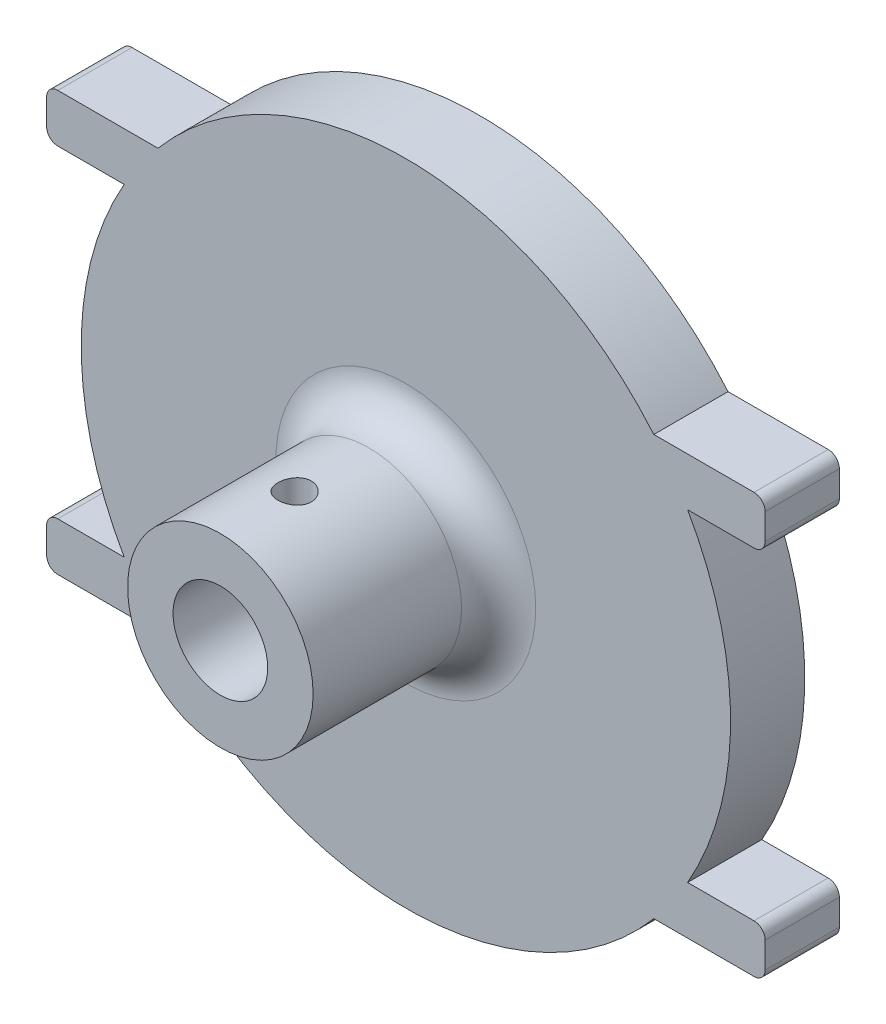
from build123d import *

# Parameters (mm, degrees)
BOSS_EXTRUDE1_DEPTH = 5.08
SKETCH5_R           = 9.6901
CUT_EXTRUDE2_DEPTH  = 2.54
SKETCH6_R           = 6.35
SKETCH6_R_2         = 3.2385
BOSS_EXTRUDE4_DEPTH = 12.7
FILLET1_R           = 2.54
SKETCH8_R           = 1.143
CUT_EXTRUDE3_DEPTH  = 7.62
SKETCH9_R           = 1.905
CUT_EXTRUDE4_DEPTH  = 16.2400001


with BuildPart() as part:
    # Sketch1 → Boss-Extrude1 (new body)
    with BuildSketch(Plane.XY):
        with BuildLine():
            Line((-23.828545778, 14.351), (-16.970545778, 14.351))
            ThreePointArc((-16.970545778, 14.351), (0, 22.225), (16.970545778, 14.351))
            Line((16.970545778, 14.351), (23.828545778, 14.351))
            ThreePointArc((23.828545778, 14.351), (24.367361145, 14.127815367), (24.590545778, 13.589))
            Line((24.590545778, 13.589), (24.590545778, 11.811))
            ThreePointArc((24.590545778, 11.811), (24.367361145, 11.272184633), (23.828545778, 11.049))
            Line((23.828545778, 11.049), (19.283936942, 11.049))
            ThreePointArc((19.283936942, 11.049), (22.225, 0), (19.283936942, -11.049))
            Line((19.283936942, -11.049), (23.828545778, -11.049))
            ThreePointArc((23.828545778, -11.049), (24.367361145, -11.272184633), (24.590545778, -11.811))
            Line((24.590545778, -11.811), (24.590545778, -13.589))
            ThreePointArc((24.590545778, -13.589), (24.367361145, -14.127815367), (23.828545778, -14.351))
            Line((23.828545778, -14.351), (16.970545778, -14.351))
            ThreePointArc((16.970545778, -14.351), (0, -22.225), (-16.970545778, -14.351))
            Line((-16.970545778, -14.351), (-23.828545778, -14.351))
            ThreePointArc((-23.828545778, -14.351), (-24.367361145, -14.127815367), (-24.590545778, -13.589))
            Line((-24.590545778, -13.589), (-24.590545778, -11.811))
            ThreePointArc((-24.590545778, -11.811), (-24.367361145, -11.272184633), (-23.828545778, -11.049))
            Line((-23.828545778, -11.049), (-19.283936942, -11.049))
            ThreePointArc((-19.283936942, -11.049), (-22.225, 0), (-19.283936942, 11.049))
            Line((-19.283936942, 11.049), (-23.828545778, 11.049))
            ThreePointArc((-23.828545778, 11.049), (-24.367361145, 11.272184633), (-24.590545778, 11.811))
            Line((-24.590545778, 11.811), (-24.590545778, 13.589))
            ThreePointArc((-24.590545778, 13.589), (-24.367361145, 14.127815367), (-23.828545778, 14.351))
        make_face()
    extrude(amount=BOSS_EXTRUDE1_DEPTH)

    # Sketch5 → Cut-Extrude2 (cut)
    with BuildSketch(Plane(origin=(0, 0, 0), x_dir=(-1, 0, 0), z_dir=(0, 0, -1))):
        Circle(SKETCH5_R)
    extrude(amount=-CUT_EXTRUDE2_DEPTH, mode=Mode.SUBTRACT)

    # Sketch6 → Boss-Extrude4 (add)
    with BuildSketch(Plane.XY.offset(5.08)):
        Circle(SKETCH6_R)
        Circle(SKETCH6_R_2, mode=Mode.SUBTRACT)
    extrude(amount=BOSS_EXTRUDE4_DEPTH)

    # Fillet1
    fillet1_edges = [part.edges().sort_by_distance(p)[0] for p in [
        (-6.35, 0, 5.08),
    ]]
    fillet(fillet1_edges, radius=FILLET1_R)

    # Sketch8 → Cut-Extrude3 (cut)
    with BuildSketch(Plane(origin=(0, 6.35, 0), x_dir=(1, 0, 0), z_dir=(0, 1, 0))):
        with Locations((0, -12.7)):
            Circle(SKETCH8_R)
    extrude(amount=-CUT_EXTRUDE3_DEPTH, mode=Mode.SUBTRACT)

    # Sketch9 → Cut-Extrude4 (cut, through all)
    with BuildSketch(Plane(origin=(0, 0, 2.54), x_dir=(-1, 0, 0), z_dir=(0, 0, -1))):
        Circle(SKETCH9_R)
    extrude(amount=-CUT_EXTRUDE4_DEPTH, mode=Mode.SUBTRACT)


solid = part.part
